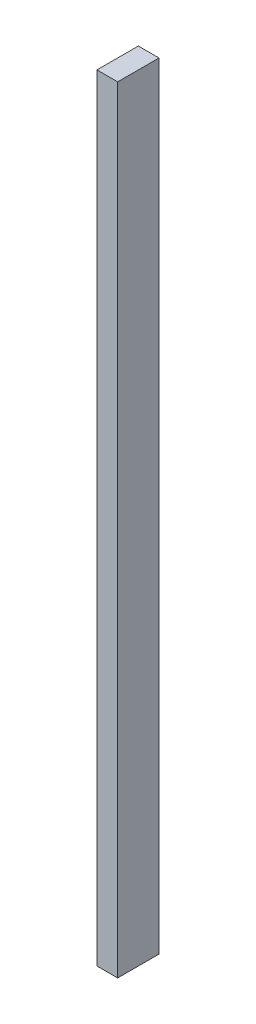
from build123d import *

# Parameters (mm, degrees)
SKETCH1_W           = 0.8
SKETCH1_H           = 30
BOSS_EXTRUDE1_DEPTH = 1.6


with BuildPart() as part:
    # Sketch1 → Boss-Extrude1 (new body)
    with BuildSketch(Plane.XY):
        with Locations((-51.926084731, -11.776301975)):
            Rectangle(SKETCH1_W, SKETCH1_H)
    extrude(amount=BOSS_EXTRUDE1_DEPTH)


solid = part.part
